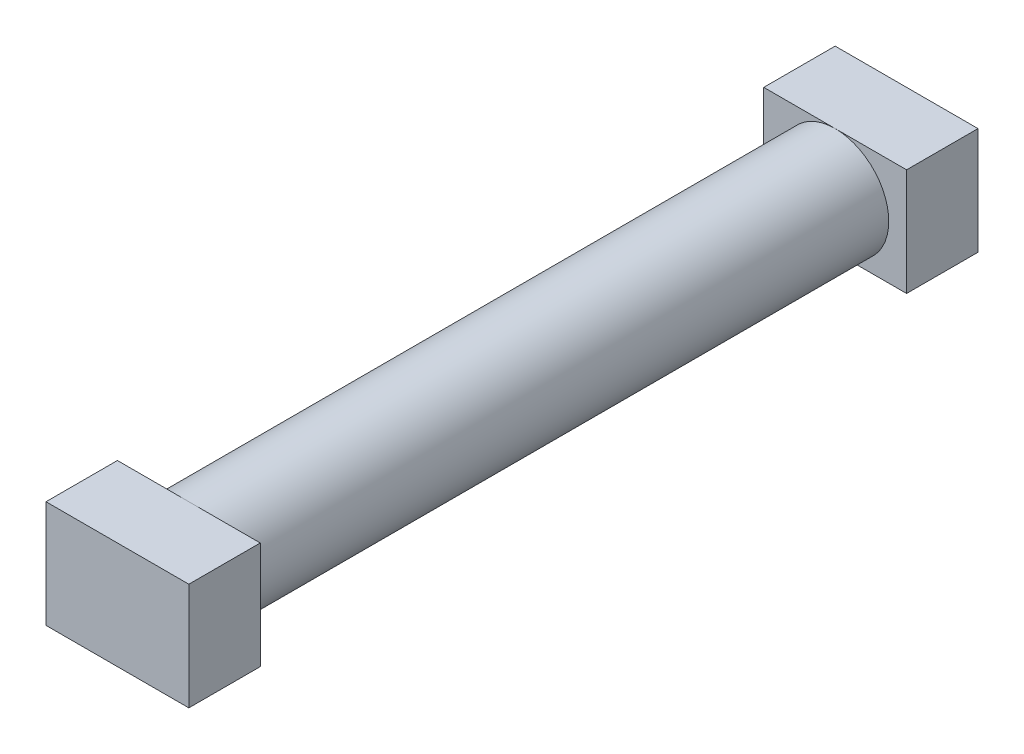
from build123d import *

# Parameters (mm, degrees)
SKETCH1_R           = 1.5
BOSS_EXTRUDE1_DEPTH = 9.05
SKETCH2_W           = 4
SKETCH2_H           = 3
BOSS_EXTRUDE2_DEPTH = 2
SKETCH3_W           = 4
SKETCH3_H           = 3
BOSS_EXTRUDE3_DEPTH = 2


with BuildPart() as part:
    # Sketch1 → Boss-Extrude1 (new body, symmetric)
    with BuildSketch(Plane.XY):
        Circle(SKETCH1_R)
    extrude(amount=BOSS_EXTRUDE1_DEPTH, both=True)

    # Sketch2 → Boss-Extrude2 (add)
    with BuildSketch(Plane.XY.offset(9.05)):
        Rectangle(SKETCH2_W, SKETCH2_H)
    extrude(amount=BOSS_EXTRUDE2_DEPTH)

    # Sketch3 → Boss-Extrude3 (add)
    with BuildSketch(Plane(origin=(0, 0, -9.05), x_dir=(-1, 0, 0), z_dir=(0, 0, -1))):
        Rectangle(SKETCH3_W, SKETCH3_H)
    extrude(amount=BOSS_EXTRUDE3_DEPTH)


solid = part.part
